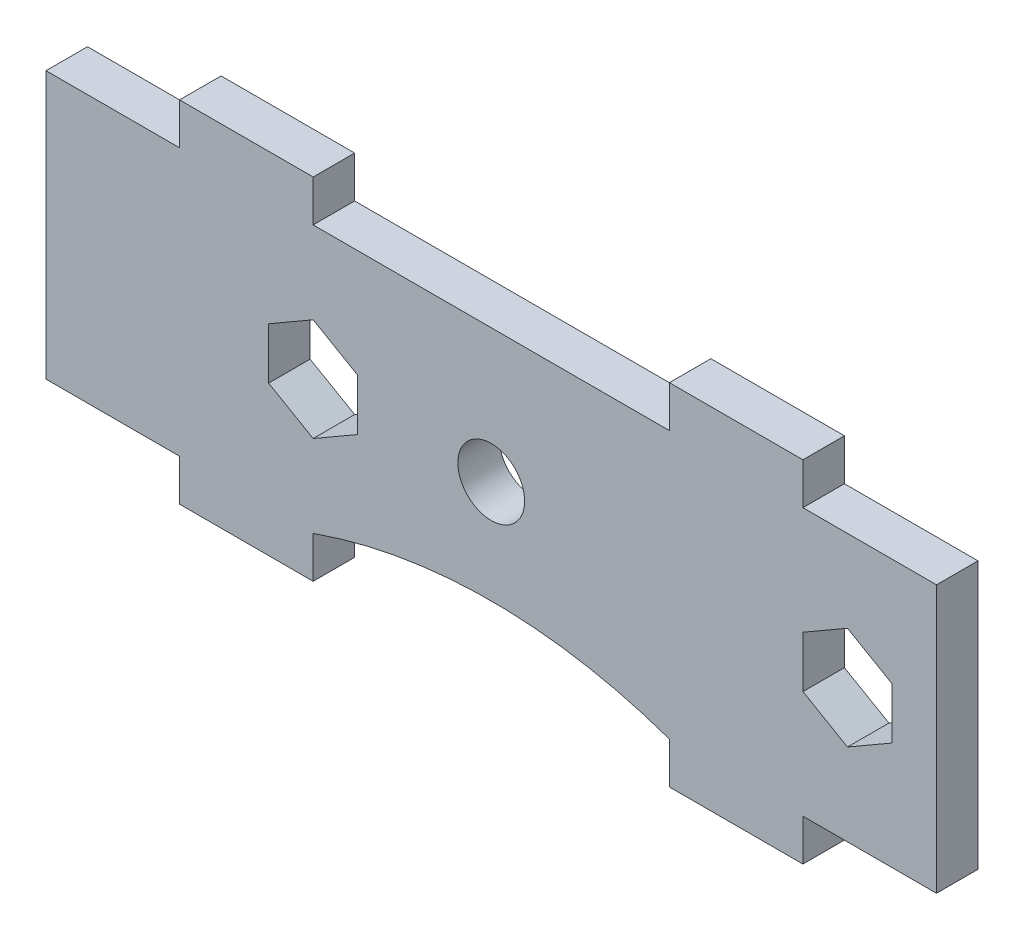
from build123d import *

# Parameters (mm, degrees)
SKETCH1_R           = 2.38125
BOSS_EXTRUDE1_DEPTH = 1.47955
CUT_EXTRUDE1_REACH  = 4.959
CUT_EXTRUDE2_REACH  = 4.959
CUT_EXTRUDE3_DEPTH  = 3.9591


with BuildPart() as part:
    # Sketch1 → Boss-Extrude1 (new body, symmetric)
    with BuildSketch(Plane.XY):
        Polygon((-12.7, 9.525), (12.7, 9.525), (12.7, 12.4841), (22.225, 12.4841), (22.225, 9.525), (31.75, 9.525), (31.75, -9.525), (22.225, -9.525), (22.225, -12.4841), (12.7, -12.4841), (12.7, -9.525), (-12.7, -9.525), (-12.7, -12.4841), (-22.225, -12.4841), (-22.225, -9.525), (-31.75, -9.525), (-31.75, 9.525), (-22.225, 9.525), (-22.225, 12.4841), (-12.7, 12.4841), align=None)
        Circle(SKETCH1_R, mode=Mode.SUBTRACT)
    extrude(amount=BOSS_EXTRUDE1_DEPTH, both=True)

    # Sketch2 → Cut-Extrude1 (cut, up to next)
    with BuildSketch(Plane.XY.offset(1.47955), mode=Mode.PRIVATE) as cut_extrude1_sk1:
        Polygon((-12.7, -3.666174209), (-9.525, -1.833087105), (-9.525, 1.833087105), (-12.7, 3.666174209), (-15.875, 1.833087105), (-15.875, -1.833087105), align=None)
    cut_extrude1_tool1 = extrude(cut_extrude1_sk1.sketch, amount=-CUT_EXTRUDE1_REACH, mode=Mode.PRIVATE) & part.part
    add(cut_extrude1_tool1.solids().sort_by_distance((-12.7, 0, 1.47955))[0], mode=Mode.SUBTRACT)

    # Sketch3 → Cut-Extrude2 (cut, up to next)
    with BuildSketch(Plane.XY.offset(1.47955), mode=Mode.PRIVATE) as cut_extrude2_sk1:
        Polygon((25.4, -3.666174209), (28.575, -1.833087105), (28.575, 1.833087105), (25.4, 3.666174209), (22.225, 1.833087105), (22.225, -1.833087105), align=None)
    cut_extrude2_tool1 = extrude(cut_extrude2_sk1.sketch, amount=-CUT_EXTRUDE2_REACH, mode=Mode.PRIVATE) & part.part
    add(cut_extrude2_tool1.solids().sort_by_distance((25.4, 0, 1.47955))[0], mode=Mode.SUBTRACT)

    # Sketch4 → Cut-Extrude3 (cut, through all)
    with BuildSketch(Plane.XY.offset(1.47955)):
        with BuildLine():
            Line((-12.7, -9.525), (12.7, -9.525))
            ThreePointArc((12.7, -9.525), (0, -7.346024484), (-12.7, -9.525))
        make_face()
    extrude(amount=-CUT_EXTRUDE3_DEPTH, mode=Mode.SUBTRACT)


solid = part.part
